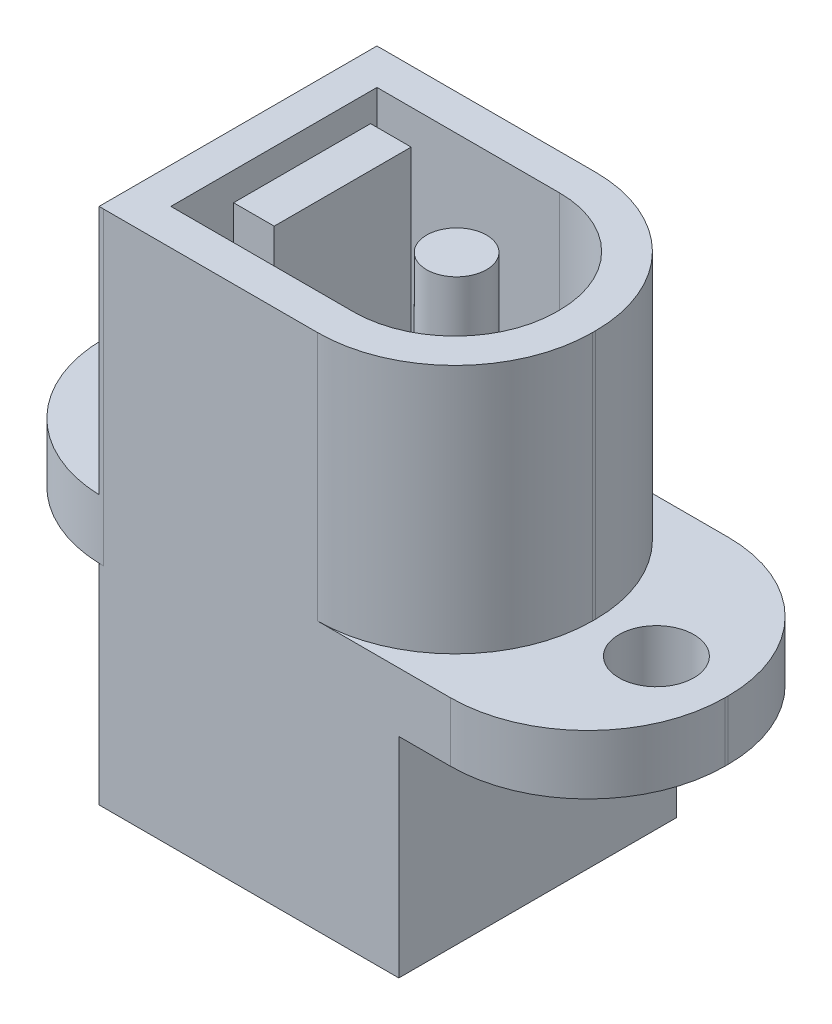
from build123d import *

# Parameters (mm, degrees)
SKETCH1_R           = 1.2
BOSS_EXTRUDE1_DEPTH = 1.9
SKETCH2_W           = 1.3
SKETCH2_H           = 4.38685961
SKETCH2_R           = 0.96
BOSS_EXTRUDE2_DEPTH = 8
SKETCH3_W           = 9.6
SKETCH3_H           = 8.897442439
BOSS_EXTRUDE3_DEPTH = 6.7


with BuildPart() as part:
    # Sketch1 → Boss-Extrude1 (new body)
    with BuildSketch(Plane(origin=(0, 0, 0), x_dir=(1, 0, 0), z_dir=(0, 1, 0))):
        with BuildLine():
            Line((-5.55, 4.45), (5.55, 4.45))
            ThreePointArc((5.55, 4.45), (8.661269837, 3.161269837), (9.95, 0.05))
            Line((9.95, 0.05), (9.95, -0.05))
            ThreePointArc((9.95, -0.05), (8.661269837, -3.161269837), (5.55, -4.45))
            Line((5.55, -4.45), (-5.55, -4.45))
            ThreePointArc((-5.55, -4.45), (-8.661269837, -3.161269837), (-9.95, -0.05))
            Line((-9.95, -0.05), (-9.95, 0.05))
            ThreePointArc((-9.95, 0.05), (-8.661269837, 3.161269837), (-5.55, 4.45))
        make_face()
        with Locations((-7.7, 0)):
            Circle(SKETCH1_R, mode=Mode.SUBTRACT)
        with Locations((7.7, 0)):
            Circle(SKETCH1_R, mode=Mode.SUBTRACT)
    extrude(amount=BOSS_EXTRUDE1_DEPTH)

    # Sketch2 → Boss-Extrude2 (add)
    with BuildSketch(Plane(origin=(0, 1.9, 0), x_dir=(1, 0, 0), z_dir=(0, 1, 0))):
        with BuildLine():
            Line((1.3, 4.45), (-5.55, 4.45))
            ThreePointArc((-5.55, 4.45), (-5.625010901, 4.449360563), (-5.7, 4.447442439))
            Line((-5.7, 4.447442439), (-5.7, -4.447442439))
            ThreePointArc((-5.7, -4.447442439), (-5.625010901, -4.449360563), (-5.55, -4.45))
            Line((-5.55, -4.45), (1.3, -4.45))
            ThreePointArc((1.3, -4.45), (4.411269837, -3.161269837), (5.7, -0.05))
            Line((5.7, -0.05), (5.7, 0.05))
            ThreePointArc((5.7, 0.05), (4.411269837, 3.161269837), (1.3, 4.45))
        make_face()
        with BuildLine():
            Line((-4.55, -3.3), (-4.55, 3.3))
            Line((-4.55, 3.3), (1.3, 3.3))
            ThreePointArc((1.3, 3.3), (3.598097039, 2.348097039), (4.55, 0.05))
            Line((4.55, 0.05), (4.55, -0.05))
            ThreePointArc((4.55, -0.05), (3.598097039, -2.348097039), (1.3, -3.3))
            Line((1.3, -3.3), (-4.55, -3.3))
        make_face(mode=Mode.SUBTRACT)
        with Locations((-2.99802734, 0)):
            Rectangle(SKETCH2_W, SKETCH2_H)
        with Locations((1.3, 0)):
            Circle(SKETCH2_R)
    extrude(amount=BOSS_EXTRUDE2_DEPTH)

    # Sketch3 → Boss-Extrude3 (add)
    with BuildSketch(Plane.XZ):
        with Locations((-0.9, 0.00127878)):
            Rectangle(SKETCH3_W, SKETCH3_H)
    extrude(amount=BOSS_EXTRUDE3_DEPTH)


solid = part.part
